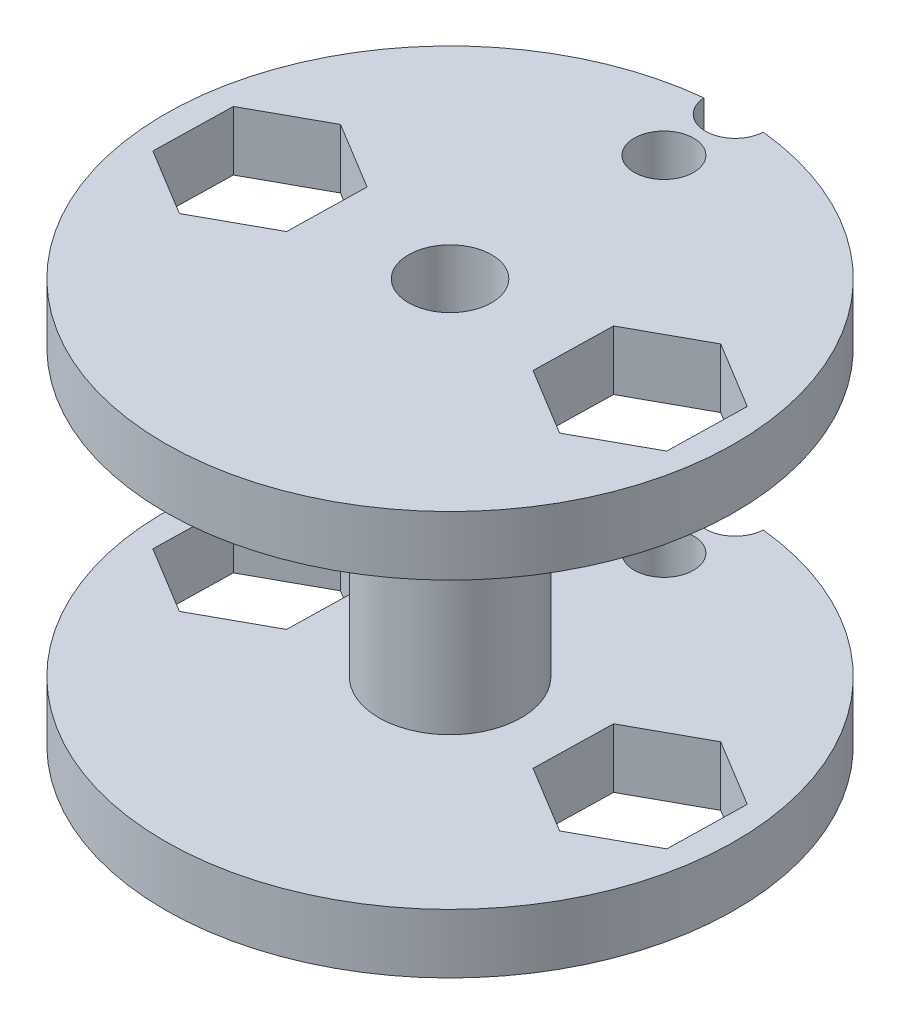
from build123d import *

# Parameters (mm, degrees)
SKETCH1_R           = 12
SKETCH1_R_2         = 1.75
BOSS_EXTRUDE1_DEPTH = 2.5
CUT_EXTRUDE3_DEPTH  = 2.5
SKETCH4_R           = 1.25
CUT_EXTRUDE4_DEPTH  = 5
SKETCH2_R           = 3
SKETCH2_R_2         = 1.75
BOSS_EXTRUDE2_DEPTH = 6


with BuildPart() as part:
    # Sketch1 → Boss-Extrude1 (new body)
    with BuildSketch(Plane(origin=(0, 0, 0), x_dir=(1, 0, 0), z_dir=(0, 1, 0))):
        Circle(SKETCH1_R)
        Circle(SKETCH1_R_2, mode=Mode.SUBTRACT)
    extrude(amount=BOSS_EXTRUDE1_DEPTH)

    # Sketch3 → Cut-Extrude3 (cut)
    with BuildSketch(Plane.XZ):
        Polygon((-5.161329605, 1.721273866), (-8.071331697, 3.318997608), (-10.910002092, 1.597723742), (-10.838670395, -1.721273866), (-7.928668303, -3.318997608), (-5.089997908, -1.597723742), align=None)
        Polygon((5.161329605, -1.721273866), (8.071331697, -3.318997608), (10.910002092, -1.597723742), (10.838670395, 1.721273866), (7.928668303, 3.318997608), (5.089997908, 1.597723742), align=None)
    extrude(amount=-CUT_EXTRUDE3_DEPTH, mode=Mode.SUBTRACT)

    # Sketch4 → Cut-Extrude4 (cut)
    with BuildSketch(Plane(origin=(0, 2.5, 0), x_dir=(1, 0, 0), z_dir=(0, 1, 0))):
        with Locations((0, 9)):
            Circle(SKETCH4_R)
        with Locations((0, 12)):
            Circle(SKETCH4_R)
    extrude(amount=-CUT_EXTRUDE4_DEPTH, mode=Mode.SUBTRACT)

    # Sketch2 → Boss-Extrude2 (add)
    with BuildSketch(Plane(origin=(0, 2.5, 0), x_dir=(1, 0, 0), z_dir=(0, 1, 0))):
        Circle(SKETCH2_R)
        Circle(SKETCH2_R_2, mode=Mode.SUBTRACT)
    extrude(amount=BOSS_EXTRUDE2_DEPTH)

    # Mirror7: part across plane


with BuildPart() as part_1:
    add(part.part)
    add(part.part.mirror(Plane.ZX.offset(8.5)))


solid = part_1.part
